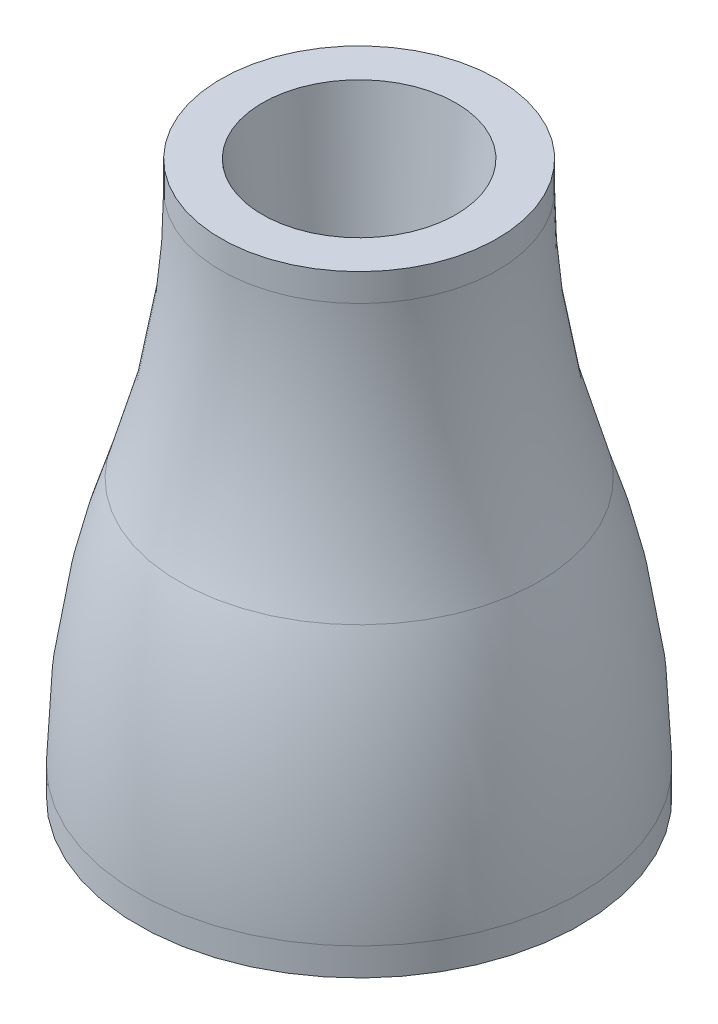
from build123d import *


with BuildPart() as part:
    # Sketch1 → Revolve1 (revolve)
    with BuildSketch(Plane.XY):
        with BuildLine():
            Line((2.4, -2), (2.4, 0))
            Line((2.4, 0), (8, 0))
            Line((8, 0), (8, 1))
            ThreePointArc((8, 1), (7.622431386, 5.562071898), (6.5, 10))
            ThreePointArc((6.5, 10), (5.377568614, 14.437928102), (5, 19))
            Line((5, 19), (5, 20))
            Line((5, 20), (3.5, 20))
            Line((3.5, 20), (0.9, -2))
            Line((0.9, -2), (2.4, -2))
        make_face()
    revolve(axis=Axis((0, 0, 0), (0, 1, 0)))


solid = part.part
